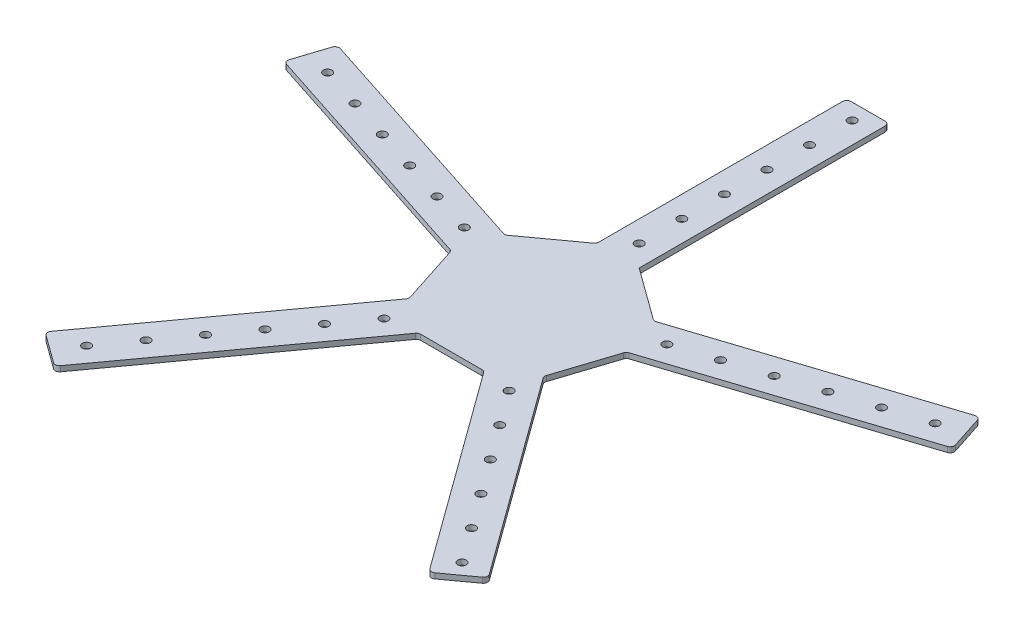
from build123d import *

# Parameters (mm, degrees)
BOSS_EXTRUDE1_DEPTH = 3.175
SKETCH4_R           = 2.54
CUT_EXTRUDE12_DEPTH = 3.175


with BuildPart() as part:
    # Sketch2 → Boss-Extrude1 (new body)
    with BuildSketch(Plane(origin=(0, 0, 0), x_dir=(1, 0, 0), z_dir=(0, 1, 0))):
        with BuildLine():
            Line((-12.7, 52.094194642), (-12.7, 197.451116118))
            ThreePointArc((-12.7, 197.451116118), (-11.956051224, 199.247167342), (-10.16, 199.991116118))
            Line((-10.16, 199.991116118), (10.16, 199.991116118))
            ThreePointArc((10.16, 199.991116118), (11.956051224, 199.247167342), (12.7, 197.451116118))
            Line((12.7, 197.451116118), (12.7, 50.8))
            Line((12.7, 50.8), (43.34212974, 28.537189595))
            ThreePointArc((43.34212974, 28.537189595), (44.43776074, 28.083364376), (45.620007447, 28.17640921))
            Line((45.620007447, 28.17640921), (188.881529889, 74.724899563))
            ThreePointArc((188.881529889, 74.724899563), (190.819568924, 74.572372583), (192.082116606, 73.094119178))
            Line((192.082116606, 73.094119178), (198.361341932, 53.768650767))
            ThreePointArc((198.361341932, 53.768650767), (198.208814952, 51.830611732), (196.730561546, 50.568064049))
            Line((196.730561546, 50.568064049), (53.469039104, 4.019573696))
            ThreePointArc((53.469039104, 4.019573696), (52.457891045, 3.399941368), (51.838258718, 2.38879331))
            Line((51.838258718, 2.38879331), (40.533934783, -32.402338363))
            ThreePointArc((40.533934783, -32.402338363), (40.44088995, -33.58458507), (40.894715169, -34.680216069))
            Line((40.894715169, -34.680216069), (126.178179335, -152.062834263))
            ThreePointArc((126.178179335, -152.062834263), (126.632004555, -153.953152345), (125.61625071, -155.610711969))
            Line((125.61625071, -155.610711969), (109.177025385, -167.554508296))
            ThreePointArc((109.177025385, -167.554508296), (107.286707303, -168.008333515), (105.629147678, -166.992579671))
            Line((105.629147678, -166.992579671), (20.345683512, -49.609961478))
            ThreePointArc((20.345683512, -49.609961478), (19.443916216, -48.839779447), (18.290780346, -48.562936018))
            Line((18.290780346, -48.562936018), (-18.290780346, -48.562936018))
            ThreePointArc((-18.290780346, -48.562936018), (-19.443916216, -48.839779447), (-20.345683512, -49.609961478))
            Line((-20.345683512, -49.609961478), (-109.417651575, -172.207007941))
            ThreePointArc((-109.417651575, -172.207007941), (-111.0752112, -173.222761785), (-112.965529282, -172.768936565))
            Line((-112.965529282, -172.768936565), (-129.404754607, -160.825140239))
            ThreePointArc((-129.404754607, -160.825140239), (-130.420508452, -159.167580614), (-129.966683232, -157.277262532))
            Line((-129.966683232, -157.277262532), (-40.894715169, -34.680216069))
            ThreePointArc((-40.894715169, -34.680216069), (-40.44088995, -33.58458507), (-40.533934783, -32.402338363))
            Line((-40.533934783, -32.402338363), (-51.838258718, 2.38879331))
            ThreePointArc((-51.838258718, 2.38879331), (-52.457891045, 3.399941368), (-53.469039104, 4.019573696))
            Line((-53.469039104, 4.019573696), (-197.623627397, 50.858238734))
            ThreePointArc((-197.623627397, 50.858238734), (-199.101880803, 52.120786416), (-199.254407783, 54.058825452))
            Line((-199.254407783, 54.058825452), (-192.975182457, 73.384293863))
            ThreePointArc((-192.975182457, 73.384293863), (-191.712634775, 74.862547268), (-189.77459574, 75.015074248))
            Line((-189.77459574, 75.015074248), (-45.620007447, 28.17640921))
            ThreePointArc((-45.620007447, 28.17640921), (-44.43776074, 28.083364376), (-43.34212974, 28.537189595))
            Line((-43.34212974, 28.537189595), (-13.747025459, 50.039291476))
            ThreePointArc((-13.747025459, 50.039291476), (-12.976843429, 50.941058772), (-12.7, 52.094194642))
        make_face()
    extrude(amount=BOSS_EXTRUDE1_DEPTH)

    # Sketch4 → Cut-Extrude12 (cut)
    with BuildSketch(Plane(origin=(0, 0, 0), x_dir=(1, 0, 0), z_dir=(0, 1, 0))):
        with Locations((0, 63.5)):
            Circle(SKETCH4_R)
        with Locations((60.392088785, 19.622579143)):
            Circle(SKETCH4_R)
        with Locations((37.324363521, -51.372579143)):
            Circle(SKETCH4_R)
        with Locations((-37.324363521, -51.372579143)):
            Circle(SKETCH4_R)
        with Locations((-60.392088785, 19.622579143)):
            Circle(SKETCH4_R)
        with Locations((0, 88.9)):
            Circle(SKETCH4_R)
        with Locations((0, 114.3)):
            Circle(SKETCH4_R)
        with Locations((0, 139.7)):
            Circle(SKETCH4_R)
        with Locations((0, 165.1)):
            Circle(SKETCH4_R)
        with Locations((0, 190.5)):
            Circle(SKETCH4_R)
        with Locations((84.548924299, 27.4716108)):
            Circle(SKETCH4_R)
        with Locations((108.705759813, 35.320642457)):
            Circle(SKETCH4_R)
        with Locations((132.862595326, 43.169674114)):
            Circle(SKETCH4_R)
        with Locations((157.01943084, 51.018705771)):
            Circle(SKETCH4_R)
        with Locations((181.176266354, 58.867737428)):
            Circle(SKETCH4_R)
        with Locations((52.254108929, -71.9216108)):
            Circle(SKETCH4_R)
        with Locations((67.183854337, -92.470642457)):
            Circle(SKETCH4_R)
        with Locations((82.113599745, -113.019674114)):
            Circle(SKETCH4_R)
        with Locations((97.043345153, -133.568705771)):
            Circle(SKETCH4_R)
        with Locations((111.973090562, -154.117737428)):
            Circle(SKETCH4_R)
        with Locations((-52.254108929, -71.9216108)):
            Circle(SKETCH4_R)
        with Locations((-67.183854337, -92.470642457)):
            Circle(SKETCH4_R)
        with Locations((-82.113599745, -113.019674114)):
            Circle(SKETCH4_R)
        with Locations((-97.043345153, -133.568705771)):
            Circle(SKETCH4_R)
        with Locations((-111.973090562, -154.117737428)):
            Circle(SKETCH4_R)
        with Locations((-84.548924299, 27.4716108)):
            Circle(SKETCH4_R)
        with Locations((-108.705759813, 35.320642457)):
            Circle(SKETCH4_R)
        with Locations((-132.862595326, 43.169674114)):
            Circle(SKETCH4_R)
        with Locations((-157.01943084, 51.018705771)):
            Circle(SKETCH4_R)
        with Locations((-181.176266354, 58.867737428)):
            Circle(SKETCH4_R)
    extrude(amount=CUT_EXTRUDE12_DEPTH, mode=Mode.SUBTRACT)


solid = part.part
